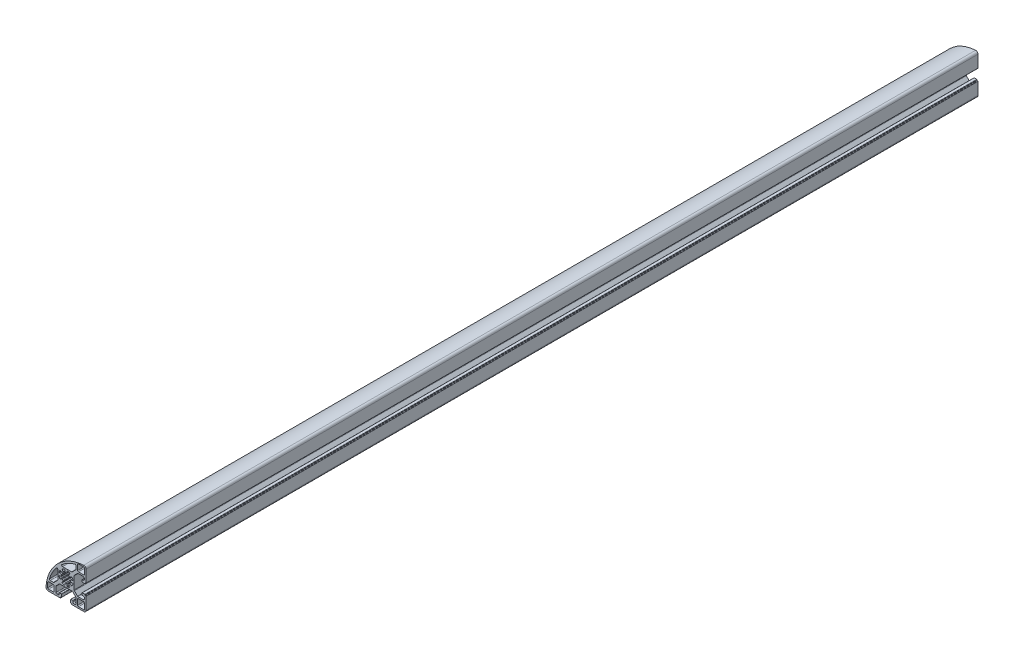
from build123d import *

# Parameters (mm, degrees)
EXTRUDE_1_DEPTH = 1000


with BuildPart() as part:
    # Эскиз1 → Бобышка-Вытянуть1 (new body)
    with BuildSketch(Plane.XY):
        with BuildLine():
            Line((11.25, -22.5), (20, -22.5))
            ThreePointArc((20, -22.5), (21.767766953, -21.767766953), (22.5, -20))
            Line((22.5, -20), (22.5, -11.25))
            Line((22.5, -11.25), (22.5, -6.4))
            ThreePointArc((22.5, -6.4), (22.412132034, -6.187867966), (22.2, -6.1))
            Line((22.2, -6.1), (21.8, -6.1))
            ThreePointArc((21.8, -6.1), (21.587867966, -6.012132034), (21.5, -5.8))
            Line((21.5, -5.8), (21.5, -5.4))
            ThreePointArc((21.5, -5.4), (21.412132034, -5.187867966), (21.2, -5.1))
            Line((21.2, -5.1), (18.3, -5.1))
            ThreePointArc((18.3, -5.1), (18.087867966, -5.187867966), (18, -5.4))
            Line((18, -5.4), (18, -7.3))
            ThreePointArc((18, -7.3), (18.087867966, -7.512132034), (18.3, -7.6))
            Line((18.3, -7.6), (19.5, -7.6))
            ThreePointArc((19.5, -7.6), (20.207106781, -7.892893219), (20.5, -8.6))
            Line((20.5, -8.6), (20.5, -10.25))
            ThreePointArc((20.5, -10.25), (20.207106781, -10.957106781), (19.5, -11.25))
            Line((19.5, -11.25), (13.564213562, -11.25))
            ThreePointArc((13.564213562, -11.25), (13.18153013, -11.173879533), (12.857106781, -10.957106781))
            Line((12.857106781, -10.957106781), (9.442893219, -7.542893219))
            ThreePointArc((9.442893219, -7.542893219), (9.226120467, -7.21846987), (9.15, -6.835786438))
            Line((9.15, -6.835786438), (9.15, 6.835786438))
            ThreePointArc((9.15, 6.835786438), (9.226120467, 7.21846987), (9.442893219, 7.542893219))
            Line((9.442893219, 7.542893219), (12.857106781, 10.957106781))
            ThreePointArc((12.857106781, 10.957106781), (13.18153013, 11.173879533), (13.564213562, 11.25))
            Line((13.564213562, 11.25), (19.5, 11.25))
            ThreePointArc((19.5, 11.25), (20.207106781, 10.957106781), (20.5, 10.25))
            Line((20.5, 10.25), (20.5, 8.6))
            ThreePointArc((20.5, 8.6), (20.207106781, 7.892893219), (19.5, 7.6))
            Line((19.5, 7.6), (18.3, 7.6))
            ThreePointArc((18.3, 7.6), (18.087867966, 7.512132034), (18, 7.3))
            Line((18, 7.3), (18, 5.4))
            ThreePointArc((18, 5.4), (18.087867966, 5.187867966), (18.3, 5.1))
            Line((18.3, 5.1), (21.2, 5.1))
            ThreePointArc((21.2, 5.1), (21.412132034, 5.187867966), (21.5, 5.4))
            Line((21.5, 5.4), (21.5, 5.8))
            ThreePointArc((21.5, 5.8), (21.587867966, 6.012132034), (21.8, 6.1))
            Line((21.8, 6.1), (22.2, 6.1))
            ThreePointArc((22.2, 6.1), (22.412132034, 6.187867966), (22.5, 6.4))
            Line((22.5, 6.4), (22.5, 11.25))
            Line((22.5, 11.25), (22.5, 19.926406871))
            ThreePointArc((22.5, 19.926406871), (21.714985851, 21.745424059), (19.852941176, 22.422077864))
            ThreePointArc((19.852941176, 22.422077864), (-9.319805153, 9.319805153), (-22.422077864, -19.852941176))
            ThreePointArc((-22.422077864, -19.852941176), (-21.745424059, -21.714985851), (-19.926406871, -22.5))
            Line((-19.926406871, -22.5), (-11.25, -22.5))
            Line((-11.25, -22.5), (-6.4, -22.5))
            ThreePointArc((-6.4, -22.5), (-6.187867966, -22.412132034), (-6.1, -22.2))
            Line((-6.1, -22.2), (-6.1, -21.8))
            ThreePointArc((-6.1, -21.8), (-6.012132034, -21.587867966), (-5.8, -21.5))
            Line((-5.8, -21.5), (-5.4, -21.5))
            ThreePointArc((-5.4, -21.5), (-5.187867966, -21.412132034), (-5.1, -21.2))
            Line((-5.1, -21.2), (-5.1, -18.3))
            ThreePointArc((-5.1, -18.3), (-5.187867966, -18.087867966), (-5.4, -18))
            Line((-5.4, -18), (-7.3, -18))
            ThreePointArc((-7.3, -18), (-7.512132034, -18.087867966), (-7.6, -18.3))
            Line((-7.6, -18.3), (-7.6, -19.5))
            ThreePointArc((-7.6, -19.5), (-7.892893219, -20.207106781), (-8.6, -20.5))
            Line((-8.6, -20.5), (-10.25, -20.5))
            ThreePointArc((-10.25, -20.5), (-10.957106781, -20.207106781), (-11.25, -19.5))
            Line((-11.25, -19.5), (-11.25, -13.564213562))
            ThreePointArc((-11.25, -13.564213562), (-11.173879533, -13.18153013), (-10.957106781, -12.857106781))
            Line((-10.957106781, -12.857106781), (-7.542893219, -9.442893219))
            ThreePointArc((-7.542893219, -9.442893219), (-7.21846987, -9.226120467), (-6.835786438, -9.15))
            Line((-6.835786438, -9.15), (6.835786438, -9.15))
            ThreePointArc((6.835786438, -9.15), (7.21846987, -9.226120467), (7.542893219, -9.442893219))
            Line((7.542893219, -9.442893219), (10.957106781, -12.857106781))
            ThreePointArc((10.957106781, -12.857106781), (11.173879533, -13.18153013), (11.25, -13.564213562))
            Line((11.25, -13.564213562), (11.25, -19.5))
            ThreePointArc((11.25, -19.5), (10.957106781, -20.207106781), (10.25, -20.5))
            Line((10.25, -20.5), (8.6, -20.5))
            ThreePointArc((8.6, -20.5), (7.892893219, -20.207106781), (7.6, -19.5))
            Line((7.6, -19.5), (7.6, -18.3))
            ThreePointArc((7.6, -18.3), (7.512132034, -18.087867966), (7.3, -18))
            Line((7.3, -18), (5.4, -18))
            ThreePointArc((5.4, -18), (5.187867966, -18.087867966), (5.1, -18.3))
            Line((5.1, -18.3), (5.1, -21.2))
            ThreePointArc((5.1, -21.2), (5.187867966, -21.412132034), (5.4, -21.5))
            Line((5.4, -21.5), (5.8, -21.5))
            ThreePointArc((5.8, -21.5), (6.012132034, -21.587867966), (6.1, -21.8))
            Line((6.1, -21.8), (6.1, -22.2))
            ThreePointArc((6.1, -22.2), (6.187867966, -22.412132034), (6.4, -22.5))
            Line((6.4, -22.5), (11.25, -22.5))
        make_face()
        with BuildLine():
            Line((14, -13), (19.8, -13))
            ThreePointArc((19.8, -13), (20.507106781, -13.292893219), (20.8, -14))
            Line((20.8, -14), (20.8, -19.8))
            ThreePointArc((20.8, -19.8), (20.507106781, -20.507106781), (19.8, -20.8))
            Line((19.8, -20.8), (14, -20.8))
            ThreePointArc((14, -20.8), (13.292893219, -20.507106781), (13, -19.8))
            Line((13, -19.8), (13, -14))
            ThreePointArc((13, -14), (13.292893219, -13.292893219), (14, -13))
        make_face(mode=Mode.SUBTRACT)
        with BuildLine():
            Line((-14.3, -13.3), (-19.5, -13.3))
            ThreePointArc((-19.5, -13.3), (-20.207106781, -13.592893219), (-20.5, -14.3))
            Line((-20.5, -14.3), (-20.5, -19.5))
            ThreePointArc((-20.5, -19.5), (-20.207106781, -20.207106781), (-19.5, -20.5))
            Line((-19.5, -20.5), (-14.3, -20.5))
            ThreePointArc((-14.3, -20.5), (-13.592893219, -20.207106781), (-13.3, -19.5))
            Line((-13.3, -19.5), (-13.3, -14.3))
            ThreePointArc((-13.3, -14.3), (-13.592893219, -13.592893219), (-14.3, -13.3))
        make_face(mode=Mode.SUBTRACT)
        with BuildLine():
            Line((14, 13), (19.8, 13))
            ThreePointArc((19.8, 13), (20.507106781, 13.292893219), (20.8, 14))
            Line((20.8, 14), (20.8, 19.8))
            ThreePointArc((20.8, 19.8), (20.507106781, 20.507106781), (19.8, 20.8))
            Line((19.8, 20.8), (14, 20.8))
            ThreePointArc((14, 20.8), (13.292893219, 20.507106781), (13, 19.8))
            Line((13, 19.8), (13, 14))
            ThreePointArc((13, 14), (13.292893219, 13.292893219), (14, 13))
        make_face(mode=Mode.SUBTRACT)
        with BuildLine():
            Line((-17.673840991, -11.25), (-14.216472537, -11.25))
            ThreePointArc((-14.216472537, -11.25), (-13.833789105, -11.173879533), (-13.509365756, -10.957106781))
            Line((-13.509365756, -10.957106781), (-9.495152193, -6.942893219))
            ThreePointArc((-9.495152193, -6.942893219), (-9.278379442, -6.61846987), (-9.202258975, -6.235786438))
            Line((-9.202258975, -6.235786438), (-9.202258975, 3.854549094))
            ThreePointArc((-9.202258975, 3.854549094), (-9.869561825, 4.797582819), (-10.980884188, 4.482038358))
            ThreePointArc((-10.980884188, 4.482038358), (-15.497902065, -2.371427307), (-18.630361015, -9.958333333))
            ThreePointArc((-18.630361015, -9.958333333), (-18.477478555, -10.845119036), (-17.673840991, -11.25))
        make_face(mode=Mode.SUBTRACT)
        with BuildLine():
            Line((10.957106781, 13.509365756), (6.942893219, 9.495152193))
            ThreePointArc((6.942893219, 9.495152193), (6.61846987, 9.278379442), (6.235786438, 9.202258975))
            Line((6.235786438, 9.202258975), (-3.854549094, 9.202258975))
            ThreePointArc((-3.854549094, 9.202258975), (-4.797582819, 9.869561825), (-4.482038358, 10.980884188))
            ThreePointArc((-4.482038358, 10.980884188), (2.371427307, 15.497902065), (9.958333333, 18.630361015))
            ThreePointArc((9.958333333, 18.630361015), (10.845119036, 18.477478555), (11.25, 17.673840991))
            Line((11.25, 17.673840991), (11.25, 14.216472537))
            ThreePointArc((11.25, 14.216472537), (11.173879533, 13.833789105), (10.957106781, 13.509365756))
        make_face(mode=Mode.SUBTRACT)
        with BuildLine():
            Line((1.3637258, 7.358005976), (1.016443046, 5.484235912))
            ThreePointArc((1.016443046, 5.484235912), (0.826149864, 5.176357864), (0.477957057, 5.077554239))
            ThreePointArc((0.477957057, 5.077554239), (0, 5.1), (-0.477957057, 5.077554239))
            ThreePointArc((-0.477957057, 5.077554239), (-0.826149864, 5.176357864), (-1.016443046, 5.484235912))
            Line((-1.016443046, 5.484235912), (-1.3637258, 7.358005976))
            ThreePointArc((-1.3637258, 7.358005976), (-1.586050772, 7.688167424), (-1.979043471, 7.751347427))
            ThreePointArc((-1.979043471, 7.751347427), (-3.061467459, 7.39103626), (-4.081635271, 6.880425388))
            ThreePointArc((-4.081635271, 6.880425388), (-4.314848064, 6.557862576), (-4.238596161, 6.167195683))
            Line((-4.238596161, 6.167195683), (-3.159206632, 4.596674173))
            ThreePointArc((-3.159206632, 4.596674173), (-3.076061576, 4.244413919), (-3.252406358, 3.928339711))
            ThreePointArc((-3.252406358, 3.928339711), (-3.606244584, 3.606244584), (-3.928339711, 3.252406358))
            ThreePointArc((-3.928339711, 3.252406358), (-4.244413919, 3.076061576), (-4.596674173, 3.159206632))
            Line((-4.596674173, 3.159206632), (-6.167195683, 4.238596161))
            ThreePointArc((-6.167195683, 4.238596161), (-6.557862576, 4.314848064), (-6.880425388, 4.081635271))
            ThreePointArc((-6.880425388, 4.081635271), (-7.39103626, 3.061467459), (-7.751347427, 1.979043471))
            ThreePointArc((-7.751347427, 1.979043471), (-7.688167424, 1.586050772), (-7.358005976, 1.3637258))
            Line((-7.358005976, 1.3637258), (-5.484235912, 1.016443046))
            ThreePointArc((-5.484235912, 1.016443046), (-5.176357864, 0.826149864), (-5.077554239, 0.477957057))
            ThreePointArc((-5.077554239, 0.477957057), (-5.1, 0), (-5.077554239, -0.477957057))
            ThreePointArc((-5.077554239, -0.477957057), (-5.176357864, -0.826149864), (-5.484235912, -1.016443046))
            Line((-5.484235912, -1.016443046), (-7.358005976, -1.3637258))
            ThreePointArc((-7.358005976, -1.3637258), (-7.688167424, -1.586050772), (-7.751347427, -1.979043471))
            ThreePointArc((-7.751347427, -1.979043471), (-7.39103626, -3.061467459), (-6.880425388, -4.081635271))
            ThreePointArc((-6.880425388, -4.081635271), (-6.557862576, -4.314848064), (-6.167195683, -4.238596161))
            Line((-6.167195683, -4.238596161), (-4.596674173, -3.159206632))
            ThreePointArc((-4.596674173, -3.159206632), (-4.244413919, -3.076061576), (-3.928339711, -3.252406358))
            ThreePointArc((-3.928339711, -3.252406358), (-3.606244584, -3.606244584), (-3.252406358, -3.928339711))
            ThreePointArc((-3.252406358, -3.928339711), (-3.076061576, -4.244413919), (-3.159206632, -4.596674173))
            Line((-3.159206632, -4.596674173), (-4.238596161, -6.167195683))
            ThreePointArc((-4.238596161, -6.167195683), (-4.314848064, -6.557862576), (-4.081635271, -6.880425388))
            ThreePointArc((-4.081635271, -6.880425388), (-3.061467459, -7.39103626), (-1.979043471, -7.751347427))
            ThreePointArc((-1.979043471, -7.751347427), (-1.586050772, -7.688167424), (-1.3637258, -7.358005976))
            Line((-1.3637258, -7.358005976), (-1.016443046, -5.484235912))
            ThreePointArc((-1.016443046, -5.484235912), (-0.826149864, -5.176357864), (-0.477957057, -5.077554239))
            ThreePointArc((-0.477957057, -5.077554239), (0, -5.1), (0.477957057, -5.077554239))
            ThreePointArc((0.477957057, -5.077554239), (0.826149864, -5.176357864), (1.016443046, -5.484235912))
            Line((1.016443046, -5.484235912), (1.3637258, -7.358005976))
            ThreePointArc((1.3637258, -7.358005976), (1.586050772, -7.688167424), (1.979043471, -7.751347427))
            ThreePointArc((1.979043471, -7.751347427), (3.061467459, -7.39103626), (4.081635271, -6.880425388))
            ThreePointArc((4.081635271, -6.880425388), (4.314848064, -6.557862576), (4.238596161, -6.167195683))
            Line((4.238596161, -6.167195683), (3.159206632, -4.596674173))
            ThreePointArc((3.159206632, -4.596674173), (3.076061576, -4.244413919), (3.252406358, -3.928339711))
            ThreePointArc((3.252406358, -3.928339711), (3.606244584, -3.606244584), (3.928339711, -3.252406358))
            ThreePointArc((3.928339711, -3.252406358), (4.244413919, -3.076061576), (4.596674173, -3.159206632))
            Line((4.596674173, -3.159206632), (6.167195683, -4.238596161))
            ThreePointArc((6.167195683, -4.238596161), (6.557862576, -4.314848064), (6.880425388, -4.081635271))
            ThreePointArc((6.880425388, -4.081635271), (7.39103626, -3.061467459), (7.751347427, -1.979043471))
            ThreePointArc((7.751347427, -1.979043471), (7.688167424, -1.586050772), (7.358005976, -1.3637258))
            Line((7.358005976, -1.3637258), (5.484235912, -1.016443046))
            ThreePointArc((5.484235912, -1.016443046), (5.176357864, -0.826149864), (5.077554239, -0.477957057))
            ThreePointArc((5.077554239, -0.477957057), (5.1, 0), (5.077554239, 0.477957057))
            ThreePointArc((5.077554239, 0.477957057), (5.176357864, 0.826149864), (5.484235912, 1.016443046))
            Line((5.484235912, 1.016443046), (7.358005976, 1.3637258))
            ThreePointArc((7.358005976, 1.3637258), (7.688167424, 1.586050772), (7.751347427, 1.979043471))
            ThreePointArc((7.751347427, 1.979043471), (7.39103626, 3.061467459), (6.880425388, 4.081635271))
            ThreePointArc((6.880425388, 4.081635271), (6.557862576, 4.314848064), (6.167195683, 4.238596161))
            Line((6.167195683, 4.238596161), (4.596674173, 3.159206632))
            ThreePointArc((4.596674173, 3.159206632), (4.244413919, 3.076061576), (3.928339711, 3.252406358))
            ThreePointArc((3.928339711, 3.252406358), (3.606244584, 3.606244584), (3.252406358, 3.928339711))
            ThreePointArc((3.252406358, 3.928339711), (3.076061576, 4.244413919), (3.159206632, 4.596674173))
            Line((3.159206632, 4.596674173), (4.238596161, 6.167195683))
            ThreePointArc((4.238596161, 6.167195683), (4.314848064, 6.557862576), (4.081635271, 6.880425388))
            ThreePointArc((4.081635271, 6.880425388), (3.061467459, 7.39103626), (1.979043471, 7.751347427))
            ThreePointArc((1.979043471, 7.751347427), (1.586050772, 7.688167424), (1.3637258, 7.358005976))
        make_face(mode=Mode.SUBTRACT)
    extrude(amount=EXTRUDE_1_DEPTH)


solid = part.part
